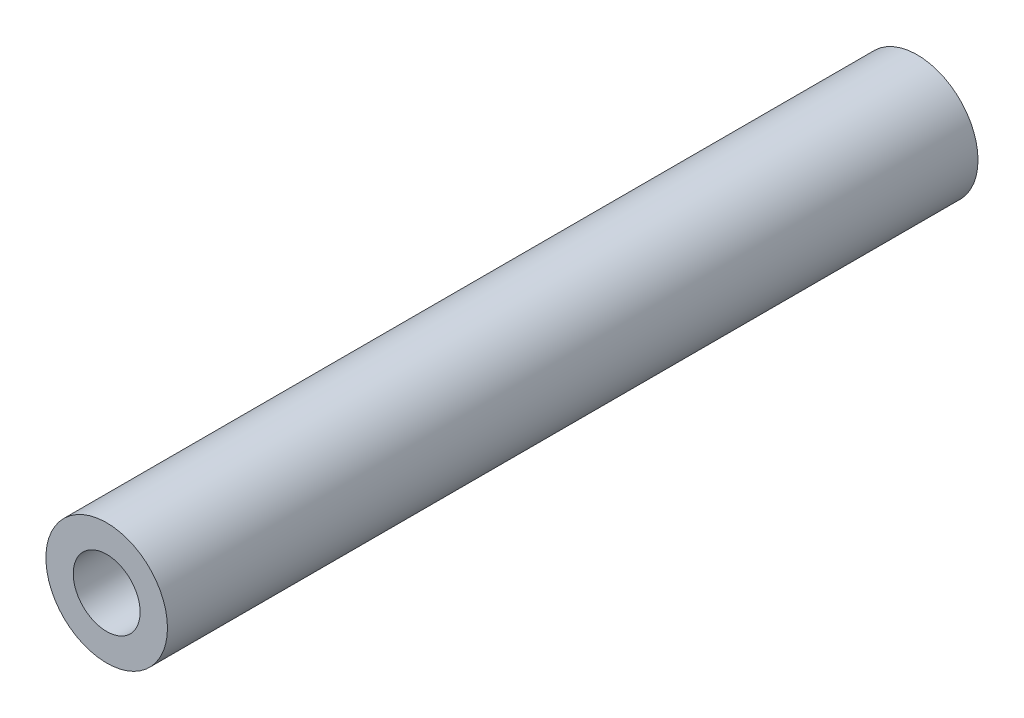
from build123d import *

# Parameters (mm, degrees)
SKETCH_1_R      = 3
SKETCH_1_R_2    = 1.65
EXTRUDE_1_DEPTH = 40


with BuildPart() as part:
    # 草图1 → 凸台-拉伸1 (new body)
    with BuildSketch(Plane.XY):
        Circle(SKETCH_1_R)
        Circle(SKETCH_1_R_2, mode=Mode.SUBTRACT)
    extrude(amount=EXTRUDE_1_DEPTH)


solid = part.part
